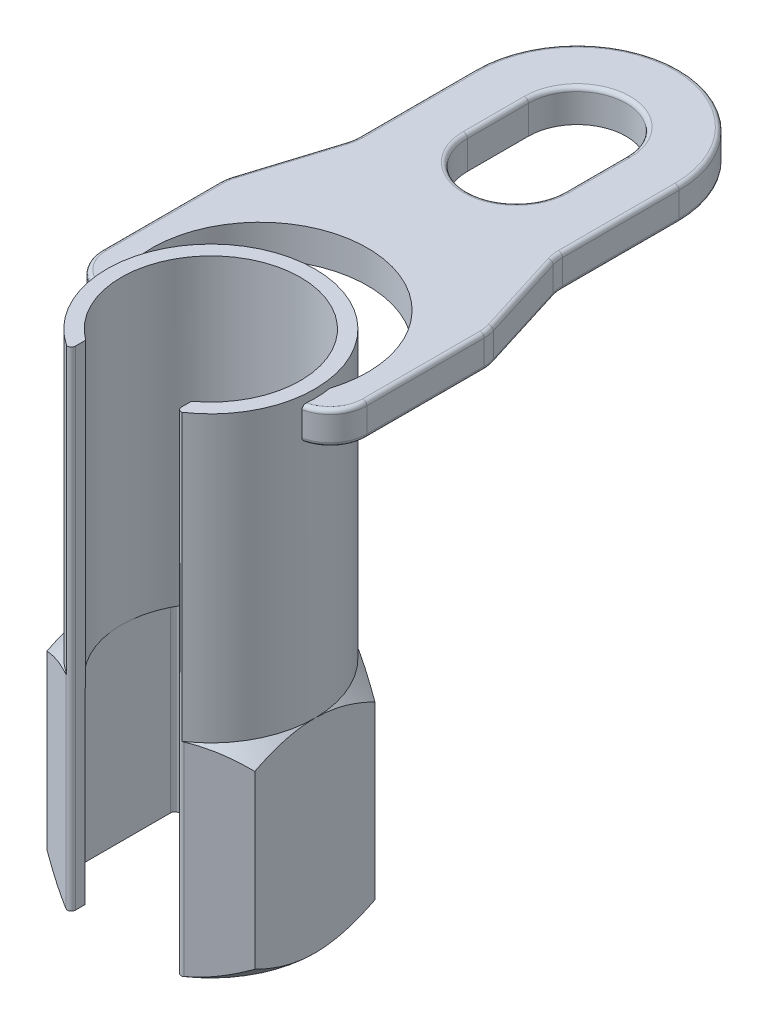
from build123d import *
from build123d.topology import SkipClean

# Parameters (mm, degrees)
EXTRUDE1_DEPTH     = 25
EXTRUDE2_DEPTH     = 35
SKETCH8_OUTSIDE_W  = 163.57
SKETCH8_OUTSIDE_H  = 163.769
SKETCH8_OUTSIDE_R  = 12.773874706
CUT_EXTRUDE4_DEPTH = 61
CUT_EXTRUDE4_DRAFT = -45
SKETCH19_OUTSIDE_W = 93.57
SKETCH19_OUTSIDE_H = 93.769
SKETCH19_OUTSIDE_R = 12.773774706
CUT_EXTRUDE6_DEPTH = 26
CUT_EXTRUDE6_DRAFT = -45
CUT_EXTRUDE9_DEPTH = 23.02377
FILLET1_R          = 0.5
EXTRUDE7_DEPTH     = 4
CUT_EXTRUDE8_REACH = 61
FILLET4_R          = 0.5


with BuildPart() as part:
    # Sketch1 → Extrude1 (new body)
    with BuildSketch(Plane(origin=(0, 0, 0), x_dir=(1, 0, 0), z_dir=(0, 1, 0))):
        with BuildLine():
            Line((-6.5, -8.874119675), (-6.5, -10.99722325))
            Line((-6.5, -10.99722325), (-12.773874706, -7.375))
            Line((-12.773874706, -7.375), (-12.773874706, 7.375))
            Line((-12.773874706, 7.375), (0, 14.75))
            Line((0, 14.75), (12.773874706, 7.375))
            Line((12.773874706, 7.375), (12.773874706, -7.375))
            Line((12.773874706, -7.375), (6.5, -10.99722325))
            Line((6.5, -10.99722325), (6.5, -8.874119675))
            ThreePointArc((6.5, -8.874119675), (0, 11), (-6.5, -8.874119675))
        make_face()
    extrude(amount=EXTRUDE1_DEPTH)

    # Sketch3 → Extrude2 (add)
    with BuildSketch(Plane(origin=(0, 25, 0), x_dir=(-1, 0, 0), z_dir=(0, 1, 0))):
        with BuildLine():
            Line((-6.5, 10.996332126), (-6.5, 8.874119675))
            ThreePointArc((-6.5, 8.874119675), (0, -11), (6.5, 8.874119675))
            Line((6.5, 8.874119675), (6.5, 10.996332126))
            ThreePointArc((6.5, 10.996332126), (0, -12.773774706), (-6.5, 10.996332126))
        make_face()
    extrude(amount=EXTRUDE2_DEPTH)


with BuildPart() as cut_extrude4_tool:
    # Sketch8 outside → Cut-Extrude4 (with draft: the straight prism first)
    with BuildSketch(Plane.XZ):
        with Locations((0, -1.8765)):
            Rectangle(SKETCH8_OUTSIDE_W, SKETCH8_OUTSIDE_H)
        Circle(SKETCH8_OUTSIDE_R, mode=Mode.SUBTRACT)
    extrude(amount=-CUT_EXTRUDE4_DEPTH)
    # Cut-Extrude4: the draft: its side faces are tilted about the plane it starts from
    cut_extrude4_sides = [cut_extrude4_tool.faces().sort_by_distance(p)[0] for p in [
        (0, 30.5, -83.761),
        (81.785, 30.5, -1.8765),
        (0, 30.5, 80.008),
        (-81.785, 30.5, -1.8765),
        (-12.773874706, 30.5, 0),
    ]]
    draft(cut_extrude4_sides, Plane.XZ, CUT_EXTRUDE4_DRAFT)


with BuildPart() as part_1:
    add(part.part)

    # Cut-Extrude4: cut by cut_extrude4_tool
    add(cut_extrude4_tool.part, mode=Mode.SUBTRACT)


with BuildPart() as cut_extrude6_tool:
    # Sketch19 outside → Cut-Extrude6 (with draft: the straight prism first)
    with BuildSketch(Plane(origin=(0, 25, 0), x_dir=(-1, 0, 0), z_dir=(0, 1, 0))):
        with Locations((0, -1.8765)):
            Rectangle(SKETCH19_OUTSIDE_W, SKETCH19_OUTSIDE_H)
        Circle(SKETCH19_OUTSIDE_R, mode=Mode.SUBTRACT)
    extrude(amount=-CUT_EXTRUDE6_DEPTH)
    # Cut-Extrude6: the draft: its side faces are tilted about the plane it starts from
    cut_extrude6_sides = [cut_extrude6_tool.faces().sort_by_distance(p)[0] for p in [
        (0, 12, -48.761),
        (-46.785, 12, -1.8765),
        (0, 12, 45.008),
        (46.785, 12, -1.8765),
        (12.773774706, 12, 0),
    ]]
    draft(cut_extrude6_sides, Plane(origin=(0, 25, 0), x_dir=(-1, 0, 0), z_dir=(0, 1, 0)), CUT_EXTRUDE6_DRAFT)


with BuildPart() as part_2:
    add(part_1.part)

    # Cut-Extrude6: cut by cut_extrude6_tool
    add(cut_extrude6_tool.part, mode=Mode.SUBTRACT)

    # Sketch26 → Cut-Extrude9 (cut)
    with BuildSketch(Plane.XZ):
        Polygon((-11, -6.350852961), (0, -12.701705922), (11, -6.350852961), (11, 6.350852961), (0, 12.701705922), (-11, 6.350852961), align=None)
    extrude(amount=-CUT_EXTRUDE9_DEPTH, mode=Mode.SUBTRACT)

    # Fillet1
    fillet1_edges = [part_2.edges().sort_by_distance(p)[0] for p in [
        (-11, 11.511885, -6.350852961),
        (-11, 11.511885, 6.350852961),
        (11, 11.511885, 6.350852961),
        (11, 11.511885, -6.350852961),
        (-6.5, 12.49995, 10.99722325),
        (6.5, 12.49995, 10.99722325),
        (0, 11.511885, -12.701705922),
    ]]
    fillet(fillet1_edges, radius=FILLET1_R)

    # Sketch16 → Extrude7 (add)
    with BuildSketch(Plane(origin=(0, 55, 0), x_dir=(-1, 0, 0), z_dir=(0, 1, 0))):
        with BuildLine():
            Line((-12.5, -45), (-12.5, -30.686749153))
            ThreePointArc((-12.5, -30.686749153), (-12.551504774, -30.007860191), (-12.704840099, -29.344511684))
            Line((-12.704840099, -29.344511684), (-16.045159901, -18.655488316))
            ThreePointArc((-16.045159901, -18.655488316), (-16.198495226, -17.992139809), (-16.25, -17.313250847))
            Line((-16.25, -17.313250847), (-16.25, -2.901707708))
            ThreePointArc((-16.25, -2.901707708), (-15.247090978, -0.069684633), (-12.685397914, 1.5))
            ThreePointArc((-12.685397914, 1.5), (0, -12.773774706), (12.685397914, 1.5))
            ThreePointArc((12.685397914, 1.5), (15.247090978, -0.069684633), (16.25, -2.901707708))
            Line((16.25, -2.901707708), (16.25, -17.313250847))
            ThreePointArc((16.25, -17.313250847), (16.198495226, -17.992139809), (16.045159901, -18.655488316))
            Line((16.045159901, -18.655488316), (12.704840099, -29.344511684))
            ThreePointArc((12.704840099, -29.344511684), (12.551504774, -30.007860191), (12.5, -30.686749153))
            Line((12.5, -30.686749153), (12.5, -45))
            ThreePointArc((12.5, -45), (0, -57.5), (-12.5, -45))
        make_face()
    extrude(amount=EXTRUDE7_DEPTH)

    # Sketch25 → Cut-Extrude8 (cut, up to next)
    with BuildSketch(Plane.XZ.offset(-59), mode=Mode.PRIVATE) as cut_extrude8_sk1:
        with BuildLine():
            Line((-6, -45), (-6, -37.5))
            ThreePointArc((-6, -37.5), (0, -31.5), (6, -37.5))
            Line((6, -37.5), (6, -45))
            ThreePointArc((6, -45), (0, -51), (-6, -45))
        make_face()
    cut_extrude8_tool1 = extrude(cut_extrude8_sk1.sketch, amount=CUT_EXTRUDE8_REACH, mode=Mode.PRIVATE) & part_2.part
    add(cut_extrude8_tool1.solids().sort_by_distance((0, 59, -41.25))[0], mode=Mode.SUBTRACT)
    # Sketch25 → Cut-Extrude8 (cut, up to next)
    with BuildSketch(Plane.XZ.offset(-59), mode=Mode.PRIVATE) as cut_extrude8_sk2:
        with BuildLine():
            ThreePointArc((12.61623241, -2), (0, -12.773774706), (-12.61623241, -2))
            ThreePointArc((-12.61623241, -2), (0, -19.235154711), (12.61623241, -2))
        make_face()
    cut_extrude8_tool2 = extrude(cut_extrude8_sk2.sketch, amount=CUT_EXTRUDE8_REACH, mode=Mode.PRIVATE) & part_2.part
    add(cut_extrude8_tool2.solids().sort_by_distance((0, 59, -13.084202))[0], mode=Mode.SUBTRACT)

    # Fillet4
    fillet4_edges = [part_2.edges().sort_by_distance(p)[0] for p in [
        (-15.247090978, 55, -0.069684633),
        (15.247090978, 55, -0.069684633),
        (16.25, 55, -10.107479277),
        (16.198495226, 55, -17.992139809),
        (14.375, 55, -24),
        (12.551504774, 55, -30.007860191),
        (12.5, 55, -37.843374576),
        (0, 55, -57.5),
        (-12.5, 55, -37.843374576),
        (-12.551504774, 55, -30.007860191),
        (-14.375, 55, -24),
        (-16.198495226, 55, -17.992139809),
        (-16.25, 55, -10.107479277),
        (-15.247090978, 59, -0.069684633),
        (15.247090978, 59, -0.069684633),
        (16.25, 59, -10.107479277),
        (16.198495226, 59, -17.992139809),
        (14.375, 59, -24),
        (12.551504774, 59, -30.007860191),
        (12.5, 59, -37.843374576),
        (0, 59, -57.5),
        (-12.5, 59, -37.843374576),
        (-12.551504774, 59, -30.007860191),
        (-14.375, 59, -24),
        (-16.198495226, 59, -17.992139809),
        (-16.25, 59, -10.107479277),
        (0, 59, -51),
        (6, 59, -41.25),
        (0, 59, -31.5),
        (-6, 59, -41.25),
    ]]
    fillet(fillet4_edges, radius=FILLET4_R)


solid = part_2.part
